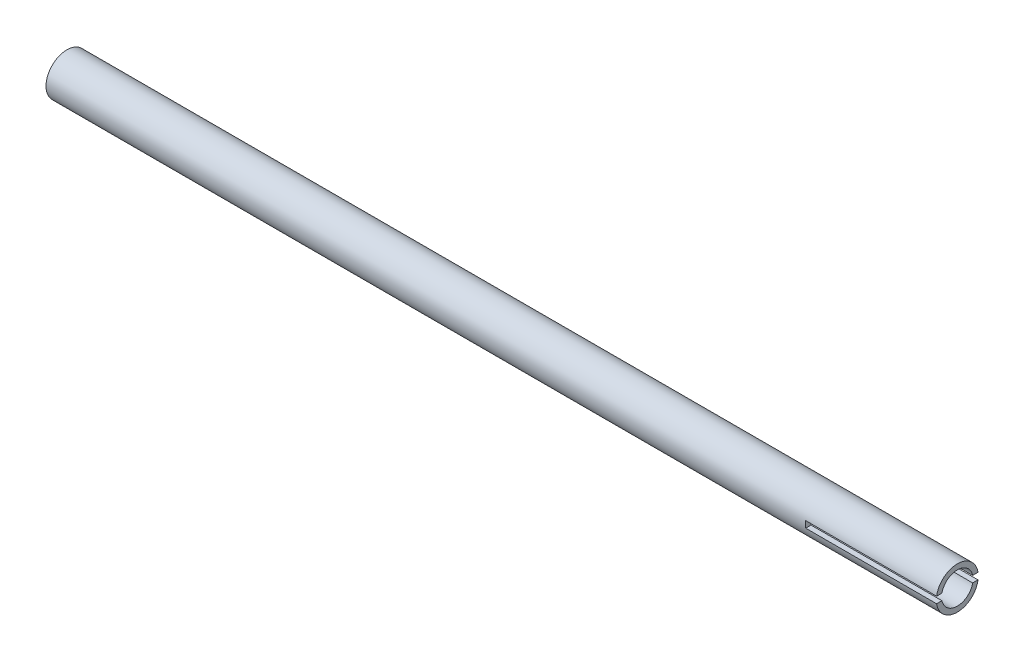
from build123d import *

# Parameters (mm, degrees)
SKETCH1_R               = 8
SKETCH1_R_2             = 6
BOSS_EXTRUDE1_DEPTH     = 170
SKETCH2_W               = 50
SKETCH2_H               = 2.5
CUT_EXTRUDE1_DEPTH      = 9
CUT_EXTRUDE1_DEPTH_BACK = 9


with BuildPart() as part:
    # Sketch1 → Boss-Extrude1 (new body, symmetric)
    with BuildSketch(Plane(origin=(0, 0, 0), x_dir=(0, 0, -1), z_dir=(1, 0, 0))):
        Circle(SKETCH1_R)
        Circle(SKETCH1_R_2, mode=Mode.SUBTRACT)
    extrude(amount=BOSS_EXTRUDE1_DEPTH, both=True)

    # Sketch2 → Cut-Extrude1 (cut, two sides)
    with BuildSketch(Plane.XY) as cut_extrude1_sk:
        with Locations((145, 0)):
            Rectangle(SKETCH2_W, SKETCH2_H)
    extrude(amount=CUT_EXTRUDE1_DEPTH, mode=Mode.SUBTRACT)
    extrude(cut_extrude1_sk.sketch, amount=-CUT_EXTRUDE1_DEPTH_BACK, mode=Mode.SUBTRACT)


solid = part.part
